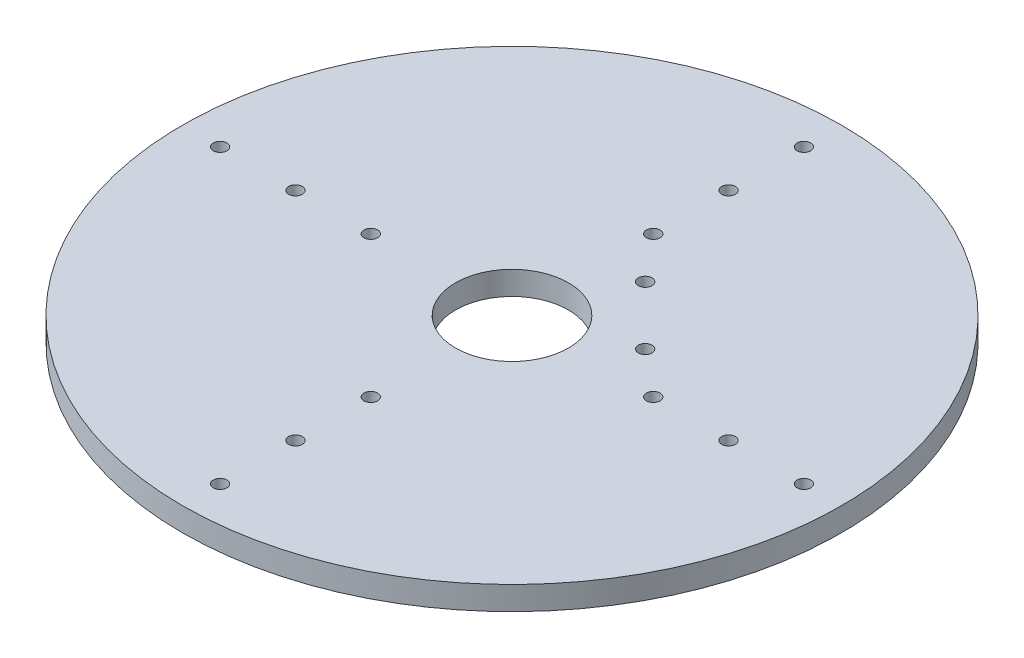
from build123d import *

# Parameters (mm, degrees)
SKETCH_1_R      = 70
SKETCH_1_R_2    = 1.45
SKETCH_1_R_3    = 12
EXTRUDE_1_DEPTH = 2.5


with BuildPart() as part:
    # 草图1 → 凸台-拉伸1 (new body, symmetric)
    with BuildSketch(Plane(origin=(0, 0, 0), x_dir=(1, 0, 0), z_dir=(0, 1, 0))):
        Circle(SKETCH_1_R)
        with Locations((7.954951288, 20.329319959)):
            Circle(SKETCH_1_R_2, mode=Mode.SUBTRACT)
        with Locations((20.329319959, 7.954951288)):
            Circle(SKETCH_1_R_2, mode=Mode.SUBTRACT)
        Circle(SKETCH_1_R_3, mode=Mode.SUBTRACT)
        with Locations((30, 0)):
            Circle(SKETCH_1_R_2, mode=Mode.SUBTRACT)
        with Locations((46, 0)):
            Circle(SKETCH_1_R_2, mode=Mode.SUBTRACT)
        with Locations((62, 0)):
            Circle(SKETCH_1_R_2, mode=Mode.SUBTRACT)
        with Locations((0, 30)):
            Circle(SKETCH_1_R_2, mode=Mode.SUBTRACT)
        with Locations((0, 46)):
            Circle(SKETCH_1_R_2, mode=Mode.SUBTRACT)
        with Locations((0, 62)):
            Circle(SKETCH_1_R_2, mode=Mode.SUBTRACT)
        with Locations((-30, 0)):
            Circle(SKETCH_1_R_2, mode=Mode.SUBTRACT)
        with Locations((-46, 0)):
            Circle(SKETCH_1_R_2, mode=Mode.SUBTRACT)
        with Locations((-62, 0)):
            Circle(SKETCH_1_R_2, mode=Mode.SUBTRACT)
        with Locations((0, -30)):
            Circle(SKETCH_1_R_2, mode=Mode.SUBTRACT)
        with Locations((0, -46)):
            Circle(SKETCH_1_R_2, mode=Mode.SUBTRACT)
        with Locations((0, -62)):
            Circle(SKETCH_1_R_2, mode=Mode.SUBTRACT)
    extrude(amount=EXTRUDE_1_DEPTH, both=True)


solid = part.part
